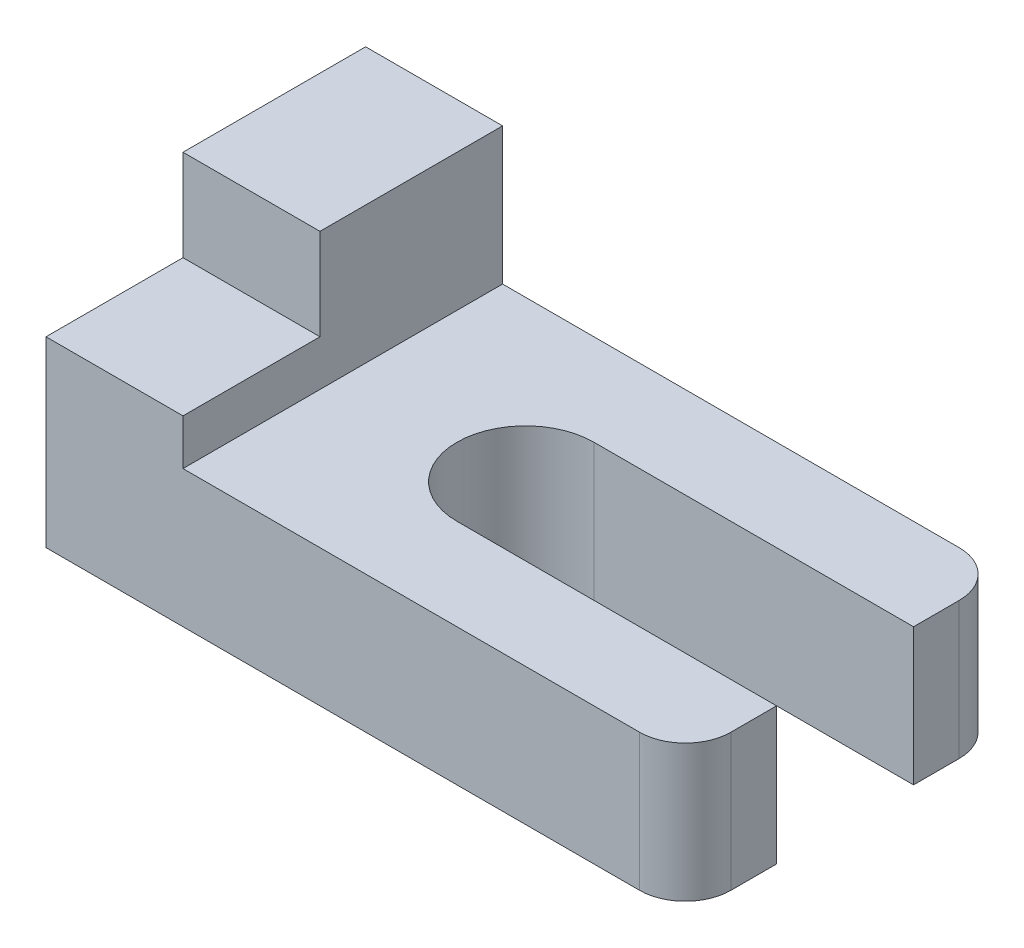
from build123d import *

# Parameters (mm, degrees)
SKETCH1_W           = 70
SKETCH1_H           = 35
BOSS_EXTRUDE1_DEPTH = 30
SKETCH2_W           = 55
SKETCH2_H           = 35
CUT_EXTRUDE1_DEPTH  = 15
SKETCH3_W           = 15
SKETCH3_H           = 15
CUT_EXTRUDE2_DEPTH  = 10
FILLET1_R           = 5
SKETCH4_W           = 35
SKETCH4_H           = 15
CUT_EXTRUDE3_DEPTH  = 16
SKETCH5_R           = 7.5
CUT_EXTRUDE4_DEPTH  = 16


with BuildPart() as part:
    # Sketch1 → Boss-Extrude1 (new body)
    with BuildSketch(Plane(origin=(0, 0, 0), x_dir=(1, 0, 0), z_dir=(0, 1, 0))):
        with Locations((35, 17.5)):
            Rectangle(SKETCH1_W, SKETCH1_H)
    extrude(amount=BOSS_EXTRUDE1_DEPTH)

    # Sketch2 → Cut-Extrude1 (cut)
    with BuildSketch(Plane(origin=(0, 30, 0), x_dir=(1, 0, 0), z_dir=(0, 1, 0))):
        with Locations((42.5, 17.5)):
            Rectangle(SKETCH2_W, SKETCH2_H)
    extrude(amount=-CUT_EXTRUDE1_DEPTH, mode=Mode.SUBTRACT)

    # Sketch3 → Cut-Extrude2 (cut)
    with BuildSketch(Plane(origin=(0, 30, 0), x_dir=(1, 0, 0), z_dir=(0, 1, 0))):
        with Locations((7.5, 7.5)):
            Rectangle(SKETCH3_W, SKETCH3_H)
    extrude(amount=-CUT_EXTRUDE2_DEPTH, mode=Mode.SUBTRACT)

    # Fillet1
    fillet1_edges = [part.edges().sort_by_distance(p)[0] for p in [
        (70, 7.5, -35),
        (70, 7.5, 0),
    ]]
    fillet(fillet1_edges, radius=FILLET1_R)

    # Sketch4 → Cut-Extrude3 (cut, through all)
    with BuildSketch(Plane(origin=(0, 15, 0), x_dir=(1, 0, 0), z_dir=(0, 1, 0))):
        with Locations((52.5, 17.5)):
            Rectangle(SKETCH4_W, SKETCH4_H)
    extrude(amount=-CUT_EXTRUDE3_DEPTH, mode=Mode.SUBTRACT)

    # Sketch5 → Cut-Extrude4 (cut, through all)
    with BuildSketch(Plane(origin=(0, 15, 0), x_dir=(1, 0, 0), z_dir=(0, 1, 0))):
        with Locations((35, 17.5)):
            Circle(SKETCH5_R)
    extrude(amount=-CUT_EXTRUDE4_DEPTH, mode=Mode.SUBTRACT)


solid = part.part
